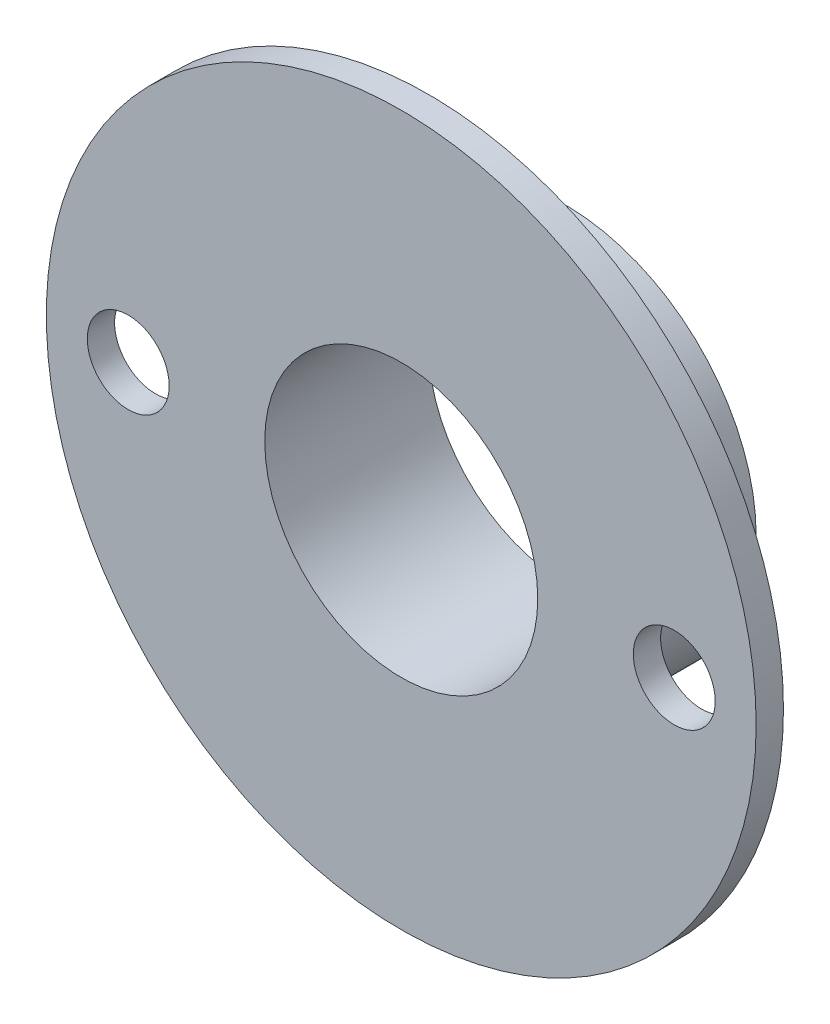
from build123d import *

# Parameters (mm, degrees)
SKETCH1_R           = 7
SKETCH1_R_2         = 5
BOSS_EXTRUDE1_DEPTH = 6
SKETCH2_R           = 13
SKETCH2_R_2         = 7
BOSS_EXTRUDE2_DEPTH = 1
SKETCH3_R           = 1.5
CUT_EXTRUDE1_DEPTH  = 1


with BuildPart() as part:
    # Sketch1 → Boss-Extrude1 (new body)
    with BuildSketch(Plane.XY):
        Circle(SKETCH1_R)
        Circle(SKETCH1_R_2, mode=Mode.SUBTRACT)
    extrude(amount=BOSS_EXTRUDE1_DEPTH)

    # Sketch2 → Boss-Extrude2 (add)
    with BuildSketch(Plane.XY.offset(6)):
        Circle(SKETCH2_R)
        Circle(SKETCH2_R_2, mode=Mode.SUBTRACT)
    extrude(amount=-BOSS_EXTRUDE2_DEPTH)

    # Sketch3 → Cut-Extrude1 (cut)
    with BuildSketch(Plane.XY.offset(6)):
        with Locations((-10, 0)):
            Circle(SKETCH3_R)
        with Locations((10, 0)):
            Circle(SKETCH3_R)
    extrude(amount=-CUT_EXTRUDE1_DEPTH, mode=Mode.SUBTRACT)


solid = part.part
